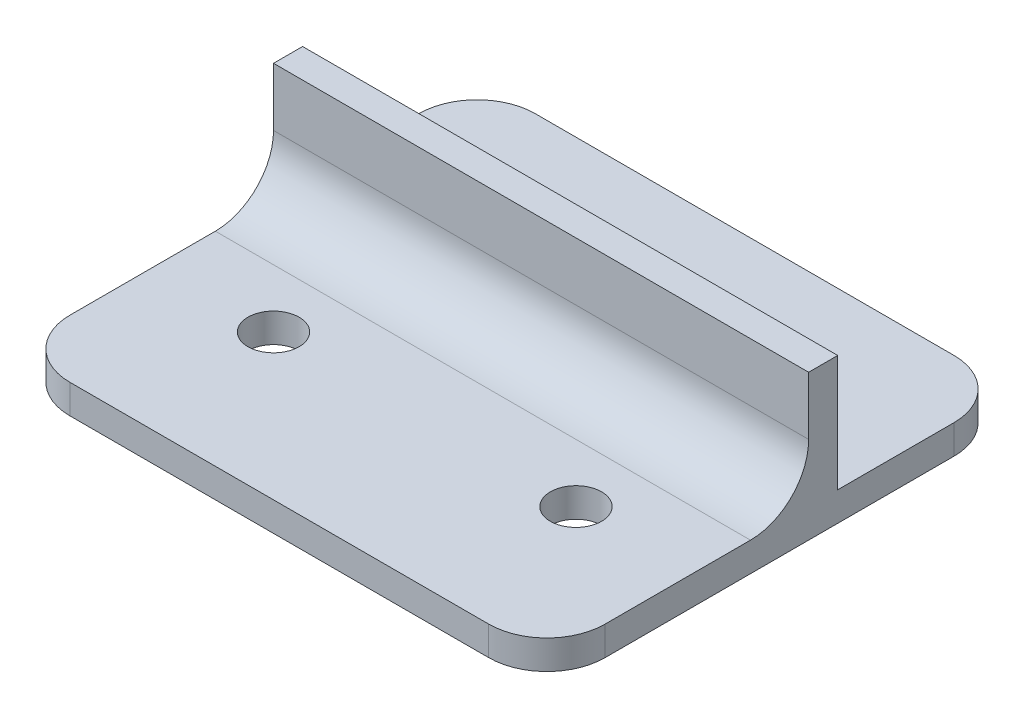
from build123d import *

# Parameters (mm, degrees)
SKETCH1_R           = 4.4
BOSS_EXTRUDE1_DEPTH = 5
SKETCH2_W           = 92
SKETCH2_H           = 5
BOSS_EXTRUDE2_DEPTH = 20
FILLET1_R           = 10
SKETCH3_R           = 5
CUT_EXTRUDE1_DEPTH  = 5
CUT_EXTRUDE1_TAPER  = 24


with BuildPart() as part:
    # Sketch1 → Boss-Extrude1 (new body)
    with BuildSketch(Plane(origin=(0, 0, 0), x_dir=(1, 0, 0), z_dir=(0, 1, 0))):
        with BuildLine():
            Line((-36, 40), (36, 40))
            ThreePointArc((36, 40), (43.071067812, 37.071067812), (46, 30))
            Line((46, 30), (46, -30))
            ThreePointArc((46, -30), (43.071067812, -37.071067812), (36, -40))
            Line((36, -40), (-36, -40))
            ThreePointArc((-36, -40), (-43.071067812, -37.071067812), (-46, -30))
            Line((-46, -30), (-46, 30))
            ThreePointArc((-46, 30), (-43.071067812, 37.071067812), (-36, 40))
        make_face()
        with Locations((-26, -15)):
            Circle(SKETCH1_R, mode=Mode.SUBTRACT)
        with Locations((26, -15)):
            Circle(SKETCH1_R, mode=Mode.SUBTRACT)
    extrude(amount=-BOSS_EXTRUDE1_DEPTH)

    # Sketch2 → Boss-Extrude2 (add)
    with BuildSketch(Plane(origin=(0, 0, 0), x_dir=(1, 0, 0), z_dir=(0, 1, 0))):
        with Locations((0, 7.5)):
            Rectangle(SKETCH2_W, SKETCH2_H)
    extrude(amount=BOSS_EXTRUDE2_DEPTH)

    # Fillet1
    fillet1_edges = [part.edges().sort_by_distance(p)[0] for p in [
        (0, 0, -5),
    ]]
    fillet(fillet1_edges, radius=FILLET1_R)

    # Sketch3 → Cut-Extrude1 (cut)
    with BuildSketch(Plane.XZ.offset(5)):
        with Locations((-26, -24)):
            Circle(SKETCH3_R)
        with Locations((26, -24)):
            Circle(SKETCH3_R)
    extrude(amount=-CUT_EXTRUDE1_DEPTH, taper=CUT_EXTRUDE1_TAPER, mode=Mode.SUBTRACT)


solid = part.part
